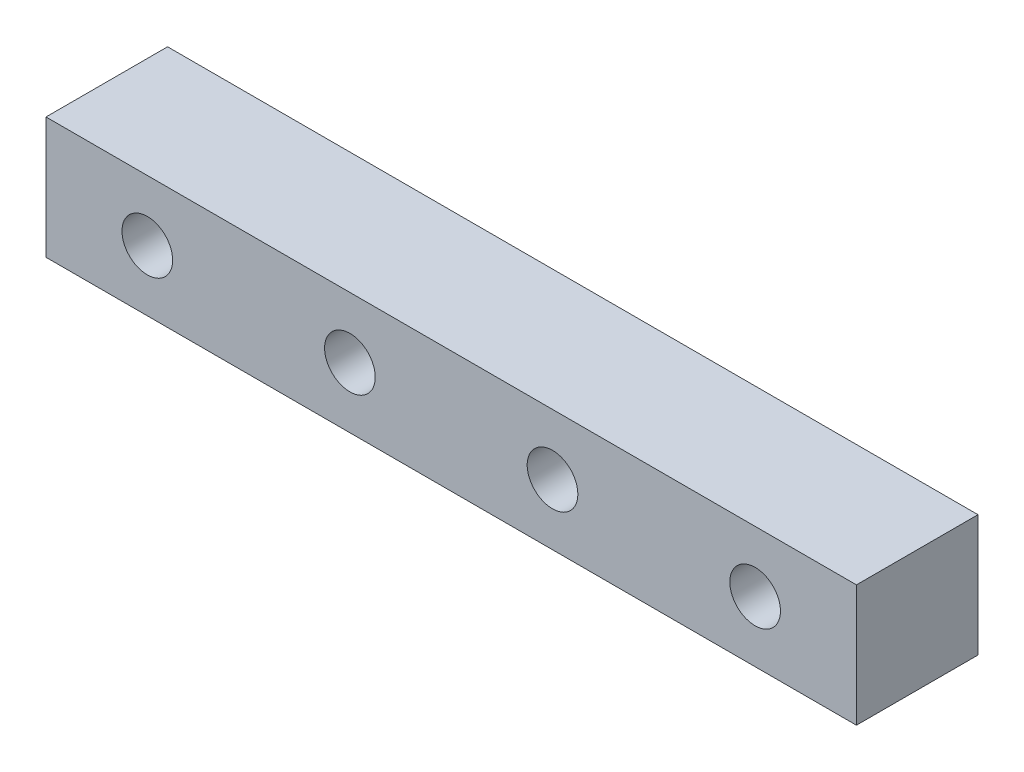
from build123d import *

# Parameters (mm, degrees)
SKETCH_1_W      = 40
SKETCH_1_H      = 6
SKETCH_1_R      = 1.25
EXTRUDE_1_DEPTH = 6


with BuildPart() as part:
    # 草图1 → 凸台-拉伸1 (new body)
    with BuildSketch(Plane.XY):
        with Locations((15, 0)):
            Rectangle(SKETCH_1_W, SKETCH_1_H)
        Circle(SKETCH_1_R, mode=Mode.SUBTRACT)
        with Locations((10, 0)):
            Circle(SKETCH_1_R, mode=Mode.SUBTRACT)
        with Locations((20, 0)):
            Circle(SKETCH_1_R, mode=Mode.SUBTRACT)
        with Locations((30, 0)):
            Circle(SKETCH_1_R, mode=Mode.SUBTRACT)
    extrude(amount=EXTRUDE_1_DEPTH)


solid = part.part
